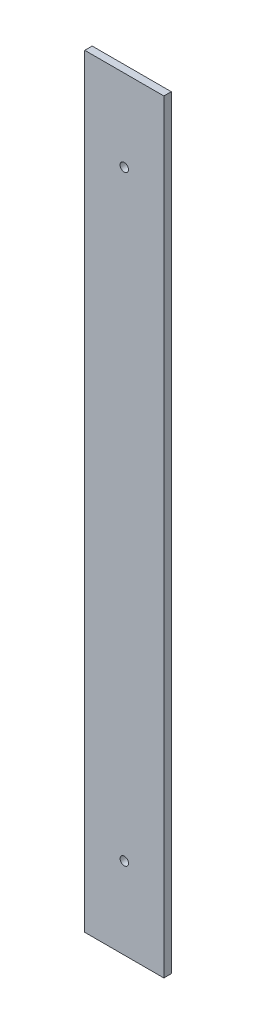
from build123d import *

# Parameters (mm, degrees)
ESQUISSE1_W             = 32
ESQUISSE1_H             = 309
BOSS_EXTRU_1_DEPTH      = 3
ESQUISSE2_R             = 1.7
ENL_V_MAT_EXTRU_1_DEPTH = 4


with BuildPart() as part:
    # Esquisse1 → Boss.-Extru.1 (new body)
    with BuildSketch(Plane.XY):
        Rectangle(ESQUISSE1_W, ESQUISSE1_H)
    extrude(amount=BOSS_EXTRU_1_DEPTH)

    # Esquisse2 → Enlèv. mat.-Extru.1 (cut, through all)
    with BuildSketch(Plane.XY.offset(3)):
        with Locations((0, 121.5)):
            Circle(ESQUISSE2_R)
        with Locations((0, -121.5)):
            Circle(ESQUISSE2_R)
    extrude(amount=-ENL_V_MAT_EXTRU_1_DEPTH, mode=Mode.SUBTRACT)


solid = part.part
